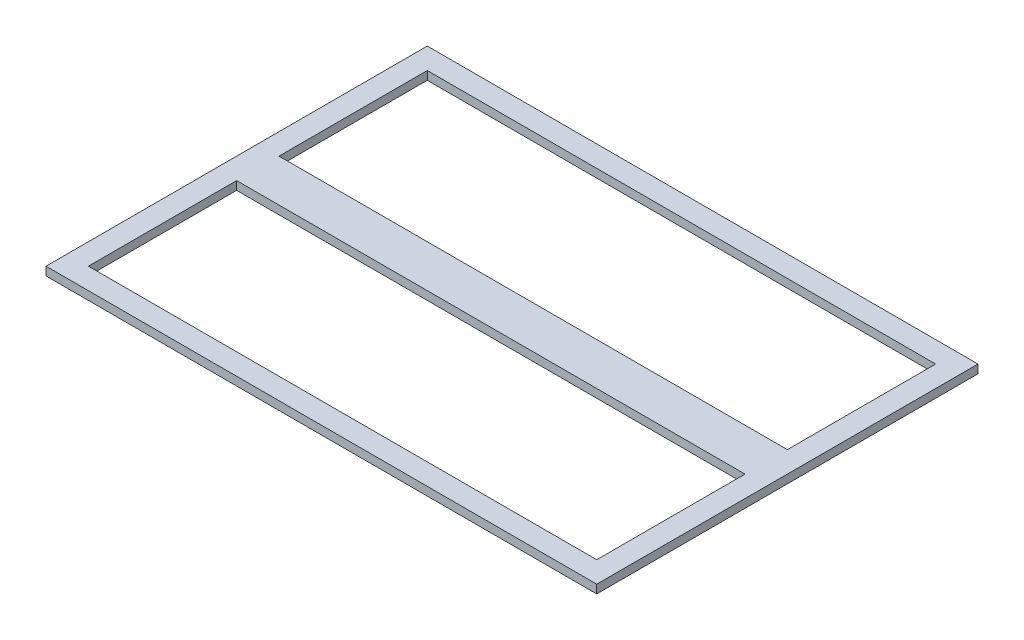
from build123d import *

# Parameters (mm, degrees)
SKETCH1_W           = 165.1
SKETCH1_H           = 114.3
SKETCH1_W_2         = 152.4
SKETCH1_H_2         = 101.6
SKETCH1_H_3         = 12.7
BOSS_EXTRUDE1_DEPTH = 2.54


with BuildPart() as part:
    # Sketch1 → Boss-Extrude1 (new body)
    with BuildSketch(Plane(origin=(0, 0, 0), x_dir=(1, 0, 0), z_dir=(0, 1, 0))):
        Rectangle(SKETCH1_W, SKETCH1_H)
        Rectangle(SKETCH1_W_2, SKETCH1_H_2, mode=Mode.SUBTRACT)
        Rectangle(SKETCH1_W_2, SKETCH1_H_3)
    extrude(amount=BOSS_EXTRUDE1_DEPTH)


solid = part.part
